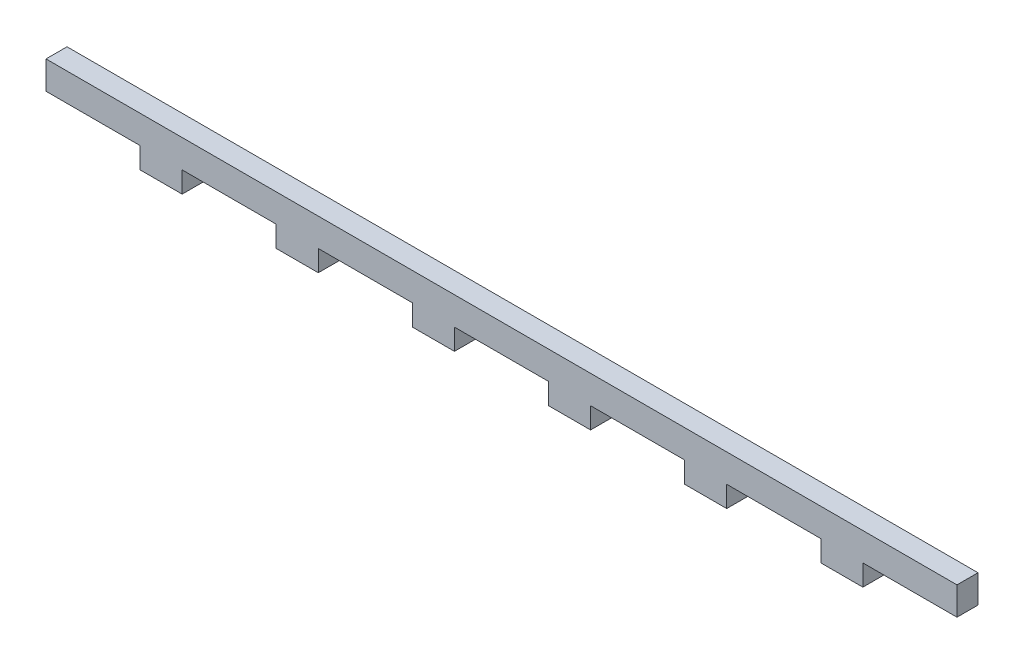
from build123d import *

# Parameters (mm, degrees)
SKETCH1_W           = 260
SKETCH1_H           = 14
BOSS_EXTRUDE1_DEPTH = 6
SKETCH3_W           = 26.857142857
SKETCH3_H           = 6
SKETCH3_W_2         = 13.428571429
CUT_EXTRUDE1_DEPTH  = 7


with BuildPart() as part:
    # Sketch1 → Boss-Extrude1 (new body)
    with BuildSketch(Plane.XY):
        Rectangle(SKETCH1_W, SKETCH1_H)
    extrude(amount=-BOSS_EXTRUDE1_DEPTH)

    # Sketch3 → Cut-Extrude1 (cut, through all)
    with BuildSketch(Plane.XY):
        with Locations((-116.571428572, -4)):
            Rectangle(SKETCH3_W, SKETCH3_H)
        with Locations((-77.714285714, -4)):
            Rectangle(SKETCH3_W, SKETCH3_H)
        with Locations((-38.857142858, -4)):
            Rectangle(SKETCH3_W, SKETCH3_H)
        with Locations((-6.714285715, -4)):
            Rectangle(SKETCH3_W_2, SKETCH3_H)
    cut_extrude1 = extrude(amount=-CUT_EXTRUDE1_DEPTH, mode=Mode.SUBTRACT)

    # Mirror1: Cut-Extrude1 across plane
    add(cut_extrude1.mirror(Plane(origin=(0, 0, 0), x_dir=(0, 0, 1), z_dir=(1, 0, 0))), mode=Mode.SUBTRACT)


solid = part.part
